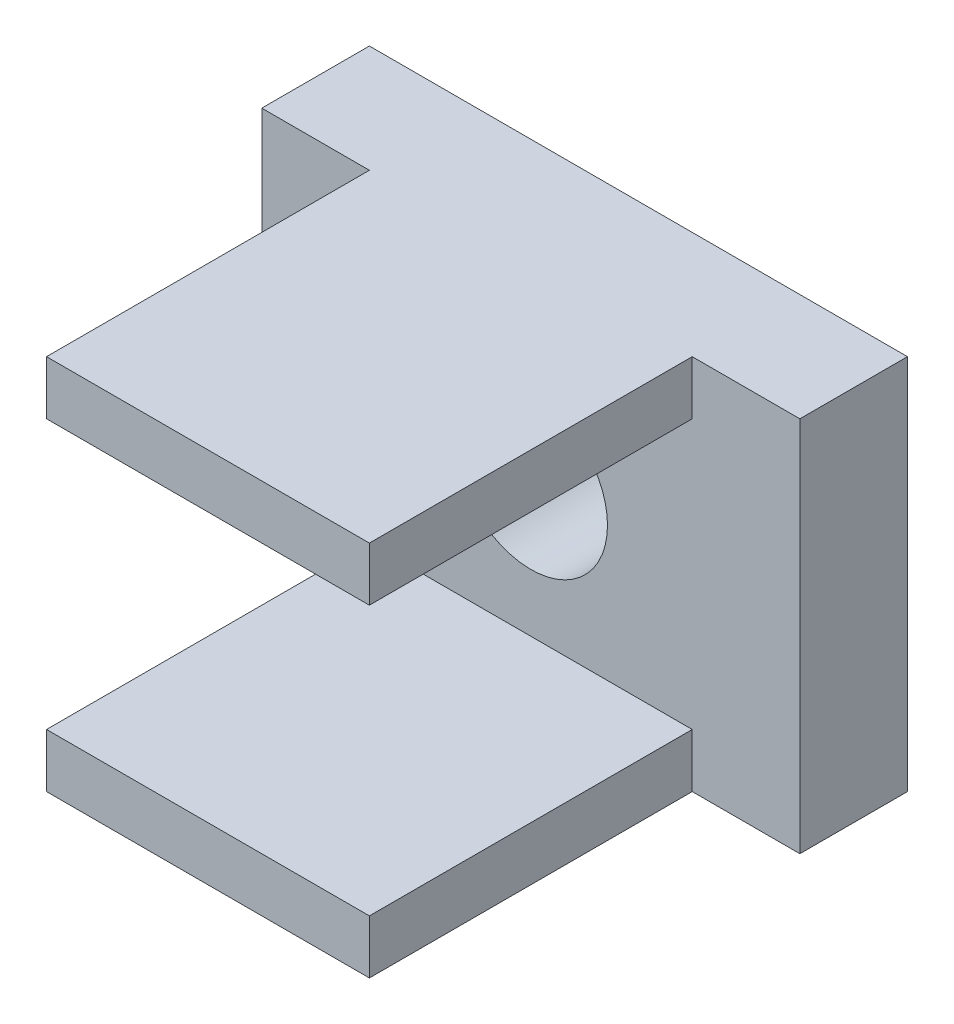
from build123d import *

# Parameters (mm, degrees)
SKETCH1_W           = 10
SKETCH1_H           = 7
BOSS_EXTRUDE1_DEPTH = 2
SKETCH2_R           = 1.425
CUT_EXTRUDE1_DEPTH  = 3
SKETCH4_W           = 6
SKETCH4_H           = 1
BOSS_EXTRUDE3_DEPTH = 6


with BuildPart() as part:
    # Sketch1 → Boss-Extrude1 (new body)
    with BuildSketch(Plane.XY):
        Rectangle(SKETCH1_W, SKETCH1_H)
    extrude(amount=BOSS_EXTRUDE1_DEPTH)

    # Sketch2 → Cut-Extrude1 (cut, through all)
    with BuildSketch(Plane.XY.offset(2)):
        Circle(SKETCH2_R)
    extrude(amount=-CUT_EXTRUDE1_DEPTH, mode=Mode.SUBTRACT)

    # Sketch4 → Boss-Extrude3 (add)
    with BuildSketch(Plane.XY.offset(2)):
        with Locations((0, 3)):
            Rectangle(SKETCH4_W, SKETCH4_H)
        with Locations((0, -3)):
            Rectangle(SKETCH4_W, SKETCH4_H)
    extrude(amount=BOSS_EXTRUDE3_DEPTH)


solid = part.part
